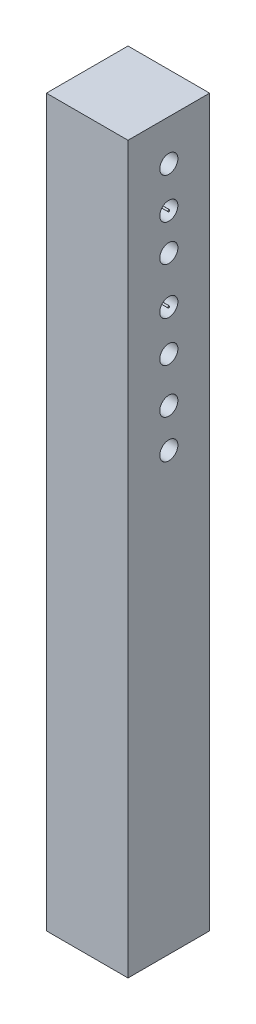
from build123d import *

# Parameters (mm, degrees)
SKETCH1_W           = 90
SKETCH1_H           = 90
BOSS_EXTRUDE1_DEPTH = 800
SKETCH2_R           = 10
SKETCH2_R_2         = 1
CUT_EXTRUDE1_DEPTH  = 91


with BuildPart() as part:
    # Sketch1 → Boss-Extrude1 (new body)
    with BuildSketch(Plane(origin=(0, 0, 0), x_dir=(1, 0, 0), z_dir=(0, 1, 0))):
        with Locations((-43.518937289, -8.641660154)):
            Rectangle(SKETCH1_W, SKETCH1_H)
    extrude(amount=-BOSS_EXTRUDE1_DEPTH)

    # Sketch2 → Cut-Extrude1 (cut, through all)
    with BuildSketch(Plane(origin=(1.481062711, 0, 0), x_dir=(0, 0, -1), z_dir=(1, 0, 0))):
        with Locations((-8.641660154, -44.967494137)):
            Circle(SKETCH2_R)
        with Locations((-8.641660154, -130.187913203)):
            Circle(SKETCH2_R)
        with Locations((-8.641660154, -226.621545304)):
            Circle(SKETCH2_R)
        with Locations((-8.641660154, -275.959682658)):
            Circle(SKETCH2_R)
        with Locations((-8.641660154, -318.569892192)):
            Circle(SKETCH2_R)
        with Locations((-8.641660154, -181.768693164)):
            Circle(SKETCH2_R)
        with Locations((-8.641660154, -181.768693164)):
            Circle(SKETCH2_R_2, mode=Mode.SUBTRACT)
        with Locations((-8.641660154, -89.820346277)):
            Circle(SKETCH2_R)
        with Locations((-8.641660154, -89.820346277)):
            Circle(SKETCH2_R_2, mode=Mode.SUBTRACT)
    extrude(amount=-CUT_EXTRUDE1_DEPTH, mode=Mode.SUBTRACT)


solid = part.part
